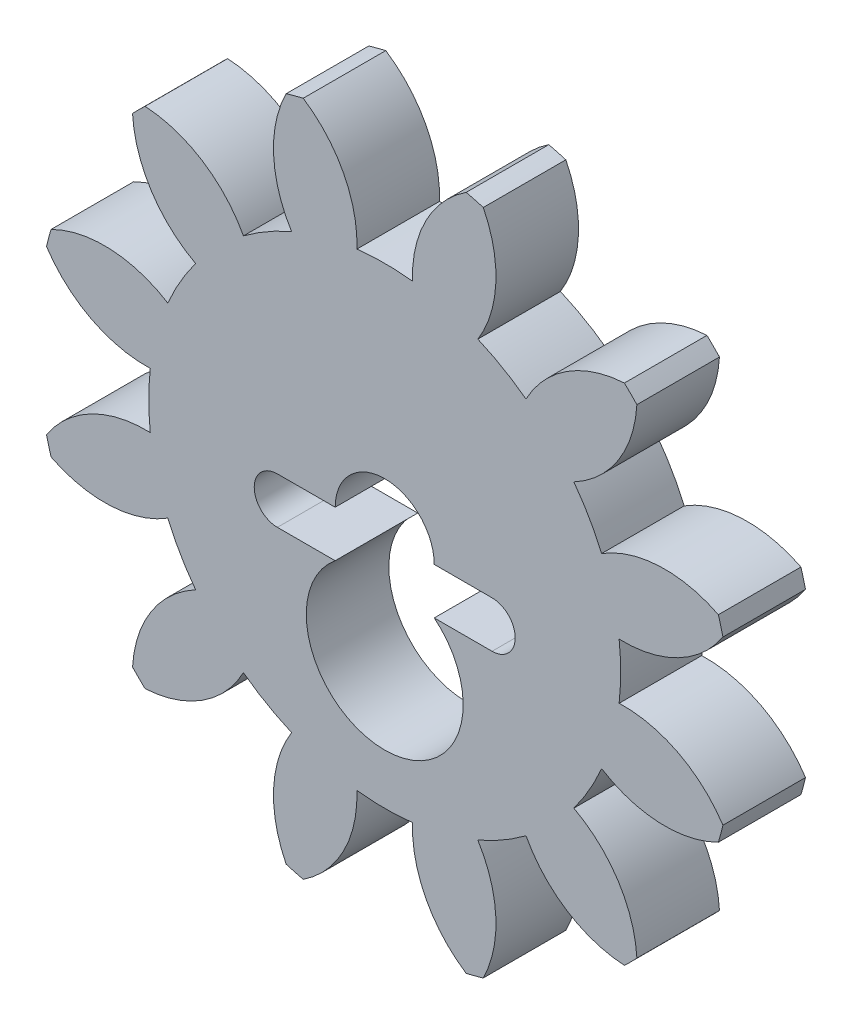
from build123d import *

# Parameters (mm, degrees)
BOSS_EXTRUDE1_DEPTH = 2.54


with BuildPart() as part:
    # Sketch1 → Boss-Extrude1 (new body)
    with BuildSketch(Plane.XY):
        with BuildLine():
            ThreePointArc((-7.372965122, 7.75726334), (-7.56755407, 7.56755407), (-7.75726334, 7.372965122))
            ThreePointArc((-7.75726334, 7.372965122), (-7.183443639, 5.605840676), (-5.817551904, 4.346341719))
            ThreePointArc((-5.817551904, 4.346341719), (-6.288954394, 3.630929512), (-6.672818294, 2.864976877))
            ThreePointArc((-6.672818294, 2.864976877), (-8.446522255, 3.41812434), (-10.263806767, 3.031504555))
            ThreePointArc((-10.263806767, 3.031504555), (-10.337471104, 2.769917034), (-10.404469677, 2.506543427))
            ThreePointArc((-10.404469677, 2.506543427), (-9.023965016, 1.263078615), (-7.211318596, 0.85526639))
            ThreePointArc((-7.211318596, 0.85526639), (-7.261859025, 0), (-7.211318596, -0.85526639))
            ThreePointArc((-7.211318596, -0.85526639), (-9.023965016, -1.263078615), (-10.404469677, -2.506543427))
            ThreePointArc((-10.404469677, -2.506543427), (-10.337471104, -2.769917034), (-10.263806767, -3.031504555))
            ThreePointArc((-10.263806767, -3.031504555), (-8.446522255, -3.41812434), (-6.672818294, -2.864976877))
            ThreePointArc((-6.672818294, -2.864976877), (-6.288954394, -3.630929512), (-5.817551904, -4.346341719))
            ThreePointArc((-5.817551904, -4.346341719), (-7.183443639, -5.605840676), (-7.75726334, -7.372965122))
            ThreePointArc((-7.75726334, -7.372965122), (-7.56755407, -7.56755407), (-7.372965122, -7.75726334))
            ThreePointArc((-7.372965122, -7.75726334), (-5.605840676, -7.183443639), (-4.346341719, -5.817551904))
            ThreePointArc((-4.346341719, -5.817551904), (-3.630929512, -6.288954394), (-2.864976877, -6.672818294))
            ThreePointArc((-2.864976877, -6.672818294), (-3.41812434, -8.446522255), (-3.031504555, -10.263806767))
            ThreePointArc((-3.031504555, -10.263806767), (-2.769917034, -10.337471104), (-2.506543427, -10.404469677))
            ThreePointArc((-2.506543427, -10.404469677), (-1.263078615, -9.023965016), (-0.85526639, -7.211318596))
            ThreePointArc((-0.85526639, -7.211318596), (0, -7.261859025), (0.85526639, -7.211318596))
            ThreePointArc((0.85526639, -7.211318596), (1.263078615, -9.023965016), (2.506543427, -10.404469677))
            ThreePointArc((2.506543427, -10.404469677), (2.769917034, -10.337471104), (3.031504555, -10.263806767))
            ThreePointArc((3.031504555, -10.263806767), (3.41812434, -8.446522255), (2.864976877, -6.672818294))
            ThreePointArc((2.864976877, -6.672818294), (3.630929512, -6.288954394), (4.346341719, -5.817551904))
            ThreePointArc((4.346341719, -5.817551904), (5.605840676, -7.183443639), (7.372965122, -7.75726334))
            ThreePointArc((7.372965122, -7.75726334), (7.56755407, -7.56755407), (7.75726334, -7.372965122))
            ThreePointArc((7.75726334, -7.372965122), (7.183443639, -5.605840676), (5.817551904, -4.346341719))
            ThreePointArc((5.817551904, -4.346341719), (6.288954394, -3.630929512), (6.672818294, -2.864976877))
            ThreePointArc((6.672818294, -2.864976877), (8.446522255, -3.41812434), (10.263806767, -3.031504555))
            ThreePointArc((10.263806767, -3.031504555), (10.337471104, -2.769917034), (10.404469677, -2.506543427))
            ThreePointArc((10.404469677, -2.506543427), (9.023965016, -1.263078615), (7.211318596, -0.85526639))
            ThreePointArc((7.211318596, -0.85526639), (7.261859025, 0), (7.211318596, 0.85526639))
            ThreePointArc((7.211318596, 0.85526639), (9.023965016, 1.263078615), (10.404469677, 2.506543427))
            ThreePointArc((10.404469677, 2.506543427), (10.337471104, 2.769917034), (10.263806767, 3.031504555))
            ThreePointArc((10.263806767, 3.031504555), (8.446522255, 3.41812434), (6.672818294, 2.864976877))
            ThreePointArc((6.672818294, 2.864976877), (6.288954394, 3.630929512), (5.817551904, 4.346341719))
            ThreePointArc((5.817551904, 4.346341719), (7.183443639, 5.605840676), (7.75726334, 7.372965122))
            ThreePointArc((7.75726334, 7.372965122), (7.56755407, 7.56755407), (7.372965122, 7.75726334))
            ThreePointArc((7.372965122, 7.75726334), (5.605840676, 7.183443639), (4.346341719, 5.817551904))
            ThreePointArc((4.346341719, 5.817551904), (3.630929512, 6.288954394), (2.864976877, 6.672818294))
            ThreePointArc((2.864976877, 6.672818294), (3.41812434, 8.446522255), (3.031504555, 10.263806767))
            ThreePointArc((3.031504555, 10.263806767), (2.769917034, 10.337471104), (2.506543427, 10.404469677))
            ThreePointArc((2.506543427, 10.404469677), (1.263078615, 9.023965016), (0.85526639, 7.211318596))
            ThreePointArc((0.85526639, 7.211318596), (0, 7.261859025), (-0.85526639, 7.211318596))
            ThreePointArc((-0.85526639, 7.211318596), (-1.263078615, 9.023965016), (-2.506543427, 10.404469677))
            ThreePointArc((-2.506543427, 10.404469677), (-2.769917034, 10.337471104), (-3.031504555, 10.263806767))
            ThreePointArc((-3.031504555, 10.263806767), (-3.41812434, 8.446522255), (-2.864976877, 6.672818294))
            ThreePointArc((-2.864976877, 6.672818294), (-3.630929512, 6.288954394), (-4.346341719, 5.817551904))
            ThreePointArc((-4.346341719, 5.817551904), (-5.605840676, 7.183443639), (-7.372965122, 7.75726334))
        make_face()
        with BuildLine():
            Line((-1.524, -1.424354318), (-3.302, -1.424354318))
            ThreePointArc((-3.302, -1.424354318), (-4.014177159, -0.712177159), (-3.302, 0))
            Line((-3.302, 0), (-1.524, 0))
            ThreePointArc((-1.524, 0), (0, 1.524), (1.524, 0))
            Line((1.524, 0), (3.302, 0))
            ThreePointArc((3.302, 0), (4.014177159, -0.712177159), (3.302, -1.424354318))
            Line((3.302, -1.424354318), (1.524, -1.424354318))
            ThreePointArc((1.524, -1.424354318), (0, -5.70818114), (-1.524, -1.424354318))
        make_face(mode=Mode.SUBTRACT)
    extrude(amount=BOSS_EXTRUDE1_DEPTH)


solid = part.part
